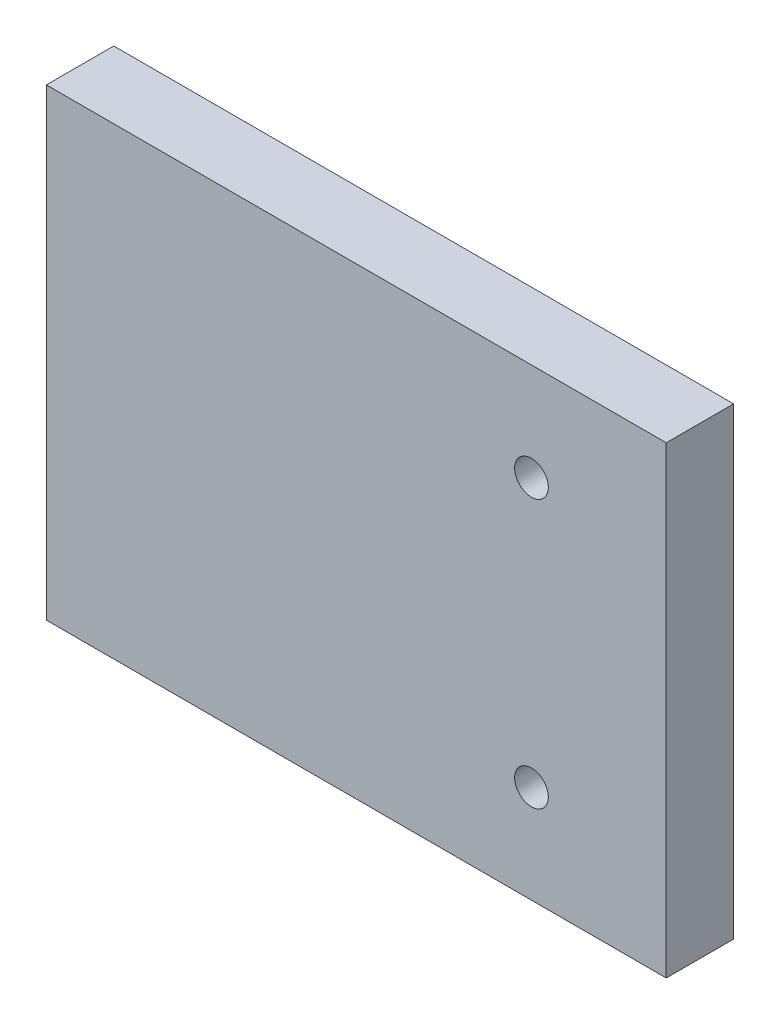
from build123d import *

# Parameters (mm, degrees)
SKETCH1_W           = 58.42
SKETCH1_H           = 43.688
SKETCH1_R           = 1.5875
BOSS_EXTRUDE1_DEPTH = 6.35


with BuildPart() as part:
    # Sketch1 → Boss-Extrude1 (new body)
    with BuildSketch(Plane.XY):
        with Locations((29.21, 21.844)):
            Rectangle(SKETCH1_W, SKETCH1_H)
        with Locations((45.72, 34.4805)):
            Circle(SKETCH1_R, mode=Mode.SUBTRACT)
        with Locations((45.72, 9.2075)):
            Circle(SKETCH1_R, mode=Mode.SUBTRACT)
    extrude(amount=BOSS_EXTRUDE1_DEPTH)


solid = part.part
